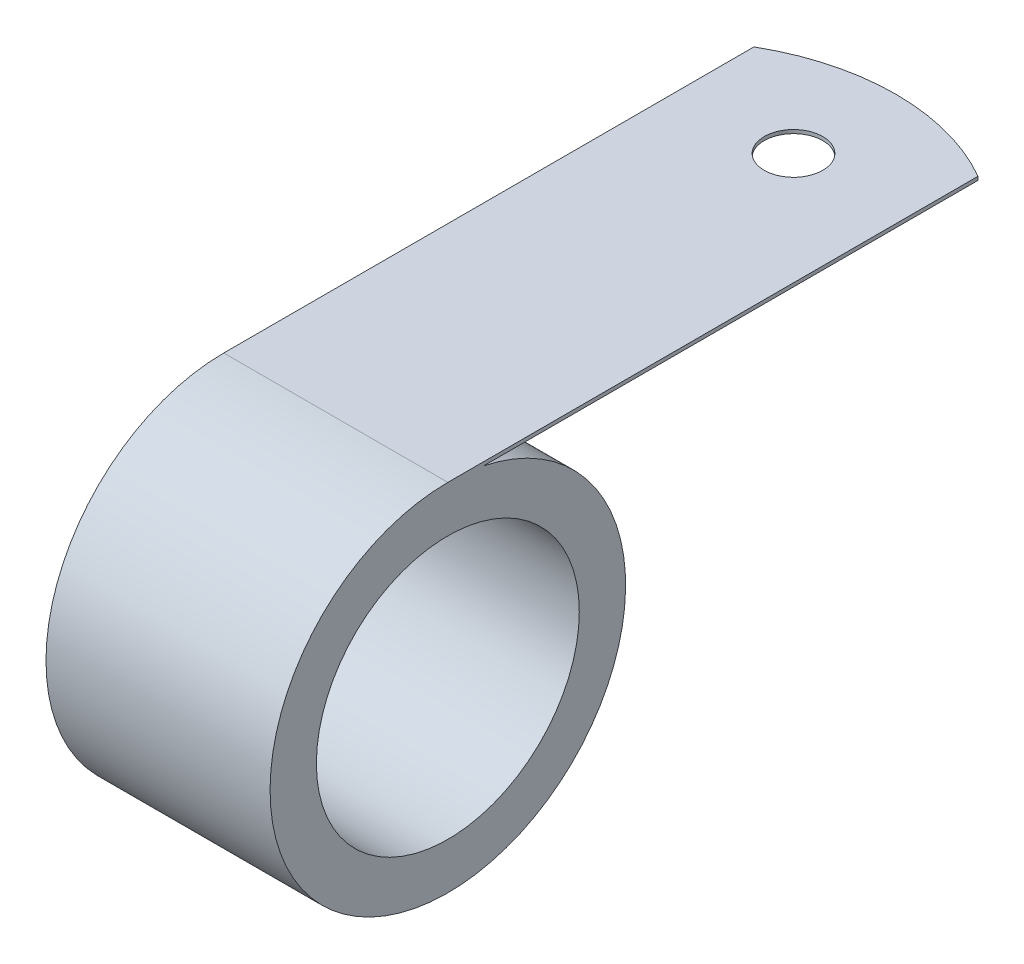
from build123d import *

# Parameters (mm, degrees)
SKETCH1_R           = 11.176
BOSS_EXTRUDE1_DEPTH = 9.525
ONEHOLE_START       = -0.3048
SKETCH2_R           = 2.4892
ONEHOLE_DEPTH       = 0.3048


with BuildPart() as part:
    # Sketch1 → Boss-Extrude1 (new, symmetric)
    with BuildSketch(Plane(origin=(0, 0, 0), x_dir=(0, 0, -1), z_dir=(1, 0, 0))):
        with BuildLine():
            Line((0, 15.113), (47.625, 15.113))
            Line((47.625, 15.113), (47.625, 14.8082))
            Line((47.625, 14.8082), (3.019930754, 14.8082))
            ThreePointArc((3.019930754, 14.8082), (-1.517636715, -15.036606924), (0, 15.113))
        make_face()
        with Locations(Location((0, 0, 0), (0, 0, 180))):
            Circle(SKETCH1_R, mode=Mode.SUBTRACT)
    extrude(amount=BOSS_EXTRUDE1_DEPTH, both=True)

    # Sketch2 → OneHole (cut)
    with BuildSketch(Plane(origin=(0, 15.113, 0), x_dir=(1, 0, 0), z_dir=(0, 1, 0)).offset(ONEHOLE_START)):
        with Locations(Location((0, 38.9128, 0), (0, 0, 270))):
            Circle(SKETCH2_R)
        with BuildLine():
            Line((-9.525, 45.072783942), (-9.525, 48.26))
            Line((-9.525, 48.26), (9.525, 48.26))
            Line((9.525, 48.26), (9.525, 45.072783942))
            ThreePointArc((9.525, 45.072783942), (0, 47.625), (-9.525, 45.072783942))
        make_face()
    extrude(amount=ONEHOLE_DEPTH, mode=Mode.SUBTRACT)


solid = part.part
